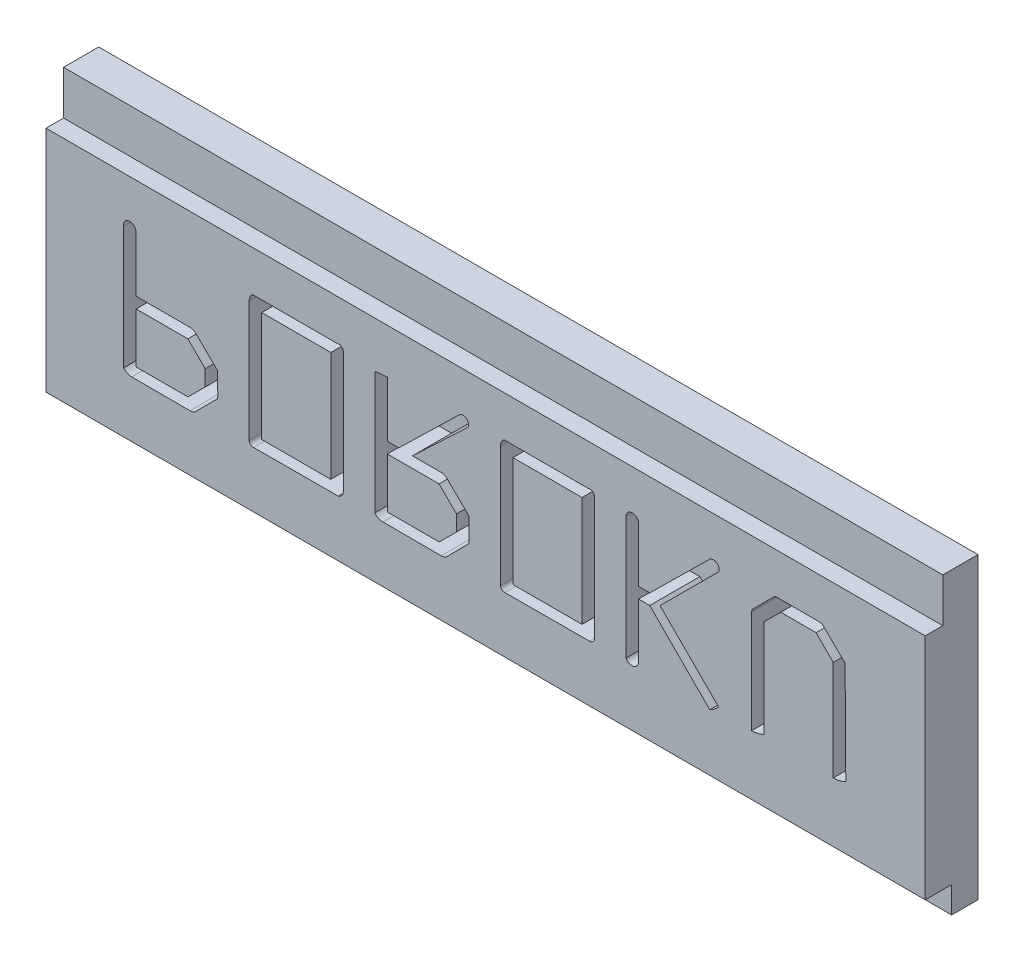
from build123d import *

# Parameters (mm, degrees)
SKETCH1_W           = 100
SKETCH1_H           = 50
BOSS_EXTRUDE1_DEPTH = 6
SKETCH2_W           = 10
SKETCH2_H           = 3
CUT_EXTRUDE1_DEPTH  = 101
SKETCH3_W           = 6
SKETCH3_H           = 34
BOSS_EXTRUDE2_DEPTH = 100
SKETCH4_W           = 2
SKETCH4_H           = 5
CUT_EXTRUDE2_DEPTH  = 101
SKETCH5_W           = 7.857142857
SKETCH5_H           = 12.5
CUT_EXTRUDE3_DEPTH  = 5.7
CUT_EXTRUDE4_DEPTH  = 5.5
CUT_EXTRUDE5_DEPTH  = 101.0000001


with BuildPart() as part:
    # Sketch1 → Boss-Extrude1 (new body)
    with BuildSketch(Plane(origin=(0, 0, 0), x_dir=(1, 0, 0), z_dir=(0, 1, 0))):
        with Locations((50, 25)):
            Rectangle(SKETCH1_W, SKETCH1_H)
    extrude(amount=BOSS_EXTRUDE1_DEPTH)

    # Sketch2 → Cut-Extrude1 (cut, through all)
    with BuildSketch(Plane(origin=(100, 0, 0), x_dir=(0, 0, -1), z_dir=(1, 0, 0))):
        with Locations((5, 1.5)):
            Rectangle(SKETCH2_W, SKETCH2_H)
    extrude(amount=-CUT_EXTRUDE1_DEPTH, mode=Mode.SUBTRACT)

    # Sketch3 → Boss-Extrude2 (add)
    with BuildSketch(Plane(origin=(100, 0, 0), x_dir=(0, 0, -1), z_dir=(1, 0, 0))):
        with Locations((47, 17)):
            Rectangle(SKETCH3_W, SKETCH3_H)
    extrude(amount=-BOSS_EXTRUDE2_DEPTH)

    # Sketch4 → Cut-Extrude2 (cut, through all)
    with BuildSketch(Plane.ZY):
        with Locations((-45, 31.5)):
            Rectangle(SKETCH4_W, SKETCH4_H)
    extrude(amount=-CUT_EXTRUDE2_DEPTH, mode=Mode.SUBTRACT)

    # Sketch5 → Cut-Extrude3 (cut)
    with BuildSketch(Plane(origin=(0, 0, -44), x_dir=(-1, 0, 0), z_dir=(0, 0, -1))):
        with BuildLine():
            Line((-45.088169643, 17.571428571), (-45.439732143, 17.454241071))
            Line((-45.439732143, 17.454241071), (-48.056919643, 14.901227679))
            Line((-48.056919643, 14.901227679), (-48.098772321, 14.76171875))
            Line((-48.098772321, 14.76171875), (-48.107142857, 12.309151786))
            Line((-48.107142857, 12.309151786), (-48.059709821, 12.0859375))
            Line((-48.059709821, 12.0859375), (-45.609933036, 9.619419643))
            ThreePointArc((-45.609933036, 9.619419643), (-45.303061085, 9.424580045), (-44.945870536, 9.357142857))
            Line((-44.945870536, 9.357142857), (-38.319196429, 9.376674107))
            ThreePointArc((-38.319196429, 9.376674107), (-37.810119286, 9.488456034), (-37.392857143, 9.80078125))
            Line((-37.392857143, 9.80078125), (-37.392857143, 23.740513393))
            ThreePointArc((-37.392857143, 23.740513393), (-38.102358714, 23.844903984), (-38.818638393, 23.880022321))
            Line((-38.818638393, 23.880022321), (-38.821428571, 17.571428571))
            Line((-38.821428571, 17.571428571), (-40.116071429, 17.571428571))
            Line((-40.116071429, 17.571428571), (-46.991071429, 24.259486607))
            ThreePointArc((-46.991071429, 24.259486607), (-47.787451466, 24.334800239), (-48.031808036, 23.573102679))
            Line((-48.031808036, 23.573102679), (-41.681361607, 17.571428571))
            Line((-41.681361607, 17.571428571), (-45.088169643, 17.571428571))
        make_face()
        Polygon((-46.678571429, 12.557477679), (-44.725446429, 10.607142857), (-38.821428571, 10.607142857), (-38.821428571, 16.321428571), (-44.708705357, 16.321428571), (-46.678571429, 14.354352679), align=None, mode=Mode.SUBTRACT)
        with BuildLine():
            Line((-17.038504464, 9.619419643), (-19.48828125, 12.0859375))
            Line((-19.48828125, 12.0859375), (-19.535714286, 12.309151786))
            Line((-19.535714286, 12.309151786), (-19.52734375, 14.758928571))
            Line((-19.52734375, 14.758928571), (-19.485491071, 14.904017857))
            Line((-19.485491071, 14.904017857), (-16.896205357, 17.454241071))
            Line((-16.896205357, 17.454241071), (-16.555803571, 17.571428571))
            Line((-16.555803571, 17.571428571), (-10.25, 17.571428571))
            Line((-10.25, 17.571428571), (-10.244419643, 23.868861607))
            ThreePointArc((-10.244419643, 23.868861607), (-9.462763686, 24.582553037), (-8.821428571, 23.740513393))
            Line((-8.821428571, 23.740513393), (-8.821428571, 9.80078125))
            ThreePointArc((-8.821428571, 9.80078125), (-9.238690714, 9.488456034), (-9.747767857, 9.376674107))
            Line((-9.747767857, 9.376674107), (-16.374441964, 9.357142857))
            ThreePointArc((-16.374441964, 9.357142857), (-16.731632514, 9.424580045), (-17.038504464, 9.619419643))
        make_face()
        Polygon((-18.107142857, 12.563058036), (-16.154017857, 10.607142857), (-10.25, 10.607142857), (-10.25, 16.321428571), (-16.137276786, 16.321428571), (-18.107142857, 14.368303571), align=None, mode=Mode.SUBTRACT)
        with BuildLine():
            Line((-33.821428571, 10.1328125), (-33.815848214, 23.880022321))
            ThreePointArc((-33.815848214, 23.880022321), (-33.601713039, 24.293327013), (-33.140625, 24.357142857))
            Line((-33.140625, 24.357142857), (-23.508928571, 24.357142857))
            ThreePointArc((-23.508928571, 24.357142857), (-23.212822653, 23.985866281), (-23.107142857, 23.522879464))
            Line((-23.107142857, 23.522879464), (-23.107142857, 9.78125))
            ThreePointArc((-23.107142857, 9.78125), (-23.280423047, 9.477022359), (-23.609375, 9.357142857))
            Line((-23.609375, 9.357142857), (-33.235491071, 9.379464286))
            ThreePointArc((-33.235491071, 9.379464286), (-33.657785084, 9.655552078), (-33.821428571, 10.1328125))
        make_face()
        with Locations((-28.464285715, 16.857142857)):
            Rectangle(SKETCH5_W, SKETCH5_H, mode=Mode.SUBTRACT)
        with BuildLine():
            Line((-62.392857143, 10.1328125), (-62.387276786, 23.880022321))
            ThreePointArc((-62.387276786, 23.880022321), (-62.17314161, 24.293327013), (-61.712053571, 24.357142857))
            Line((-61.712053571, 24.357142857), (-52.080357143, 24.357142857))
            ThreePointArc((-52.080357143, 24.357142857), (-51.784251224, 23.985866281), (-51.678571429, 23.522879464))
            Line((-51.678571429, 23.522879464), (-51.678571429, 9.78125))
            ThreePointArc((-51.678571429, 9.78125), (-51.851851619, 9.477022359), (-52.180803571, 9.357142857))
            Line((-52.180803571, 9.357142857), (-61.806919643, 9.379464286))
            ThreePointArc((-61.806919643, 9.379464286), (-62.283572717, 9.613272807), (-62.392857143, 10.1328125))
        make_face()
        with Locations((-57.035714286, 16.857142857)):
            Rectangle(SKETCH5_W, SKETCH5_H, mode=Mode.SUBTRACT)
        with BuildLine():
            Line((-76.516741071, 10.224888393), (-69.834263393, 16.890625))
            Line((-69.834263393, 16.890625), (-76.508370536, 23.564732143))
            ThreePointArc((-76.508370536, 23.564732143), (-76.263865977, 24.33823157), (-75.456473214, 24.259486607))
            Line((-75.456473214, 24.259486607), (-68.670758929, 17.571428571))
            Line((-68.670758929, 17.571428571), (-67.392857143, 17.571428571))
            Line((-67.392857143, 17.571428571), (-67.390066964, 23.880022321))
            ThreePointArc((-67.390066964, 23.880022321), (-66.613914042, 24.456808533), (-65.964285714, 23.740513393))
            Line((-65.964285714, 23.740513393), (-65.964285714, 9.789620536))
            ThreePointArc((-65.964285714, 9.789620536), (-66.815504738, 9.403127861), (-67.392857143, 10.138392857))
            Line((-67.392857143, 10.138392857), (-67.392857143, 16.321428571))
            Line((-67.392857143, 16.321428571), (-68.66796875, 16.321428571))
            Line((-68.66796875, 16.321428571), (-75.489955357, 9.465959821))
            ThreePointArc((-75.489955357, 9.465959821), (-76.031889018, 9.806810078), (-76.516741071, 10.224888393))
        make_face()
        with BuildLine():
            Line((-81.678571429, 10.130022321), (-81.678571429, 21.2265625))
            Line((-81.678571429, 21.2265625), (-83.5703125, 23.107142857))
            Line((-83.5703125, 23.107142857), (-87.585379464, 23.107142857))
            Line((-87.585379464, 23.107142857), (-89.535714286, 21.151227679))
            Line((-89.535714286, 21.151227679), (-89.535714286, 9.770089286))
            ThreePointArc((-89.535714286, 9.770089286), (-90.273009404, 9.862916097), (-90.964285714, 10.135602679))
            Line((-90.964285714, 10.135602679), (-90.883370536, 21.751116071))
            Line((-90.883370536, 21.751116071), (-88.2578125, 24.320870536))
            Line((-88.2578125, 24.320870536), (-87.872767857, 24.357142857))
            Line((-87.872767857, 24.357142857), (-82.970424107, 24.357142857))
            Line((-82.970424107, 24.357142857), (-82.7890625, 24.234375))
            Line((-82.7890625, 24.234375), (-80.303013393, 21.742745536))
            Line((-80.303013393, 21.742745536), (-80.25, 21.48046875))
            Line((-80.25, 21.48046875), (-80.25, 9.78125))
            ThreePointArc((-80.25, 9.78125), (-80.985264996, 9.869705022), (-81.678571429, 10.130022321))
        make_face()
    extrude(amount=CUT_EXTRUDE3_DEPTH, mode=Mode.SUBTRACT)

    # Sketch8 → Cut-Extrude4 (cut)
    with BuildSketch(Plane(origin=(0, 6, 0), x_dir=(1, 0, 0), z_dir=(0, 1, 0))):
        with BuildLine():
            Line((7.011617647, 30.077205882), (8.955082743, 27.33260299))
            add(Edge.make_bspline(
                [(8.955082743, 27.33260299), (9.12959235, 26.730722395), (8.207708735, 26.573406529), (7.899470003, 26.933823529)],
                knots=[0, 0, 0, 0, 1, 1, 1, 1], degree=3))
            add(Edge.make_bspline(
                [(7.899470003, 26.933823529), (6.967481131, 27.995956124), (6.173874947, 29.162344961)],
                knots=[0, 0, 0, 1, 1, 1], degree=2))
            add(Edge.make_bspline(
                [(6.173874947, 29.162344961), (5.827065663, 29.66494419), (6.530628947, 30.242627585), (7.011617647, 30.077205882)],
                knots=[0, 0, 0, 0, 1, 1, 1, 1], degree=3))
        make_face()
        with BuildLine():
            Line((8.476184036, 31.013434386), (10.320441176, 28.506054806))
            add(Edge.make_bspline(
                [(10.320441176, 28.506054806), (10.75287522, 28.022402696), (9.844480118, 27.32594185), (9.464423283, 27.806698869)],
                knots=[0, 0, 0, 0, 1, 1, 1, 1], degree=3))
            add(Edge.make_bspline(
                [(7.548449232, 30.408088235), (8.369245022, 29.00368602), (9.464423283, 27.806698869)],
                knots=[0, 0, 0, 1, 1, 1], degree=2))
            add(Edge.make_bspline(
                [(7.548449232, 30.408088235), (7.420862108, 30.780822958), (7.657281624, 31.572935659), (8.169705882, 31.400735294)],
                knots=[0, 0, 0, 0, 1, 1, 1, 1], degree=3))
            add(Edge.make_bspline(
                [(8.169705882, 31.400735294), (8.365163665, 31.240936083), (8.476184036, 31.013434386)],
                knots=[0, 0, 0, 1, 1, 1], degree=2))
        make_face()
        Polygon((10.816764706, 31.400735294), (10.155, 32.724264706), (9.327794118, 32.393382353), (9.162352941, 31.235294118), (9.824117647, 30.408088235), align=None)
        with BuildLine():
            Line((12.802058824, 32.227941176), (11.643970588, 33.716911765))
            add(Edge.make_bspline(
                [(11.643970588, 33.716911765), (10.801410064, 33.411012177), (11.092331374, 32.550744981)],
                knots=[0, 0, 0, 1, 1, 1], degree=2))
            Line((11.092331374, 32.550744981), (11.643970588, 31.731617647))
            Line((11.643970588, 31.731617647), (12.802058824, 32.227941176))
        make_face()
        with BuildLine():
            Line((13.193009945, 29.973529412), (13.854774651, 28.815441176))
            Line((13.854774651, 28.815441176), (8.560657004, 26.333823529))
            Line((8.560657004, 26.333823529), (7.402568768, 26.830147059))
            Line((7.402568768, 26.830147059), (9.056980533, 19.881617647))
            Line((9.056980533, 19.881617647), (13.689333474, 20.047058824))
            add(Edge.make_bspline(
                [(13.689333474, 20.047058824), (12.450227116, 27.171920383), (13.777231511, 23.836713066), (15.840068768, 28.65)],
                knots=[0, 0, 0, 0, 1, 1, 1, 1], degree=3))
            Line((15.840068768, 28.65), (13.854774651, 31.627941176))
            Line((13.854774651, 31.627941176), (10.711392298, 30.138970588))
            Line((10.711392298, 30.138970588), (12.365804063, 29.477205882))
            Line((12.365804063, 29.477205882), (13.193009945, 29.973529412))
        make_face()
        Polygon((31.240068768, 25.85), (31.240068768, 28.65), (28.440068768, 28.65), (28.440068768, 31.45), (25.640068768, 31.45), (25.640068768, 28.65), (22.840068768, 28.65), (22.840068768, 25.85), (25.640068768, 25.85), (25.640068768, 23.05), (28.440068768, 23.05), (28.440068768, 25.85), align=None)
        Polygon((52.041417767, 30.75), (42.541417767, 30.75), (42.541417767, 33.75), (37.990068768, 27.25), (42.541417767, 20.75), (42.541417767, 23.75), (52.041417767, 23.75), align=None)
        Polygon((60.419322104, 21.339322104), (59.041417767, 29.153805922), (61.16273811, 27.032485579), (67.880252532, 33.75), (72.83, 28.800252532), (66.112485579, 22.08273811), (68.233805922, 19.961417767), align=None)
        Polygon((90.03, 33.75), (90.03, 24.25), (93.03, 24.25), (86.476783646, 19.661388509), (80.03, 24.25), (83.03, 24.25), (83.03, 33.75), align=None)
    extrude(amount=-CUT_EXTRUDE4_DEPTH, mode=Mode.SUBTRACT)

    # Sketch9 → Cut-Extrude5 (cut, through all)
    with BuildSketch(Plane.ZY):
        Polygon((0, 6), (-44, 6), (-44, 3), (-47, 3), (-47, 0), (-44, 0), (0, 0), align=None)
    extrude(amount=-CUT_EXTRUDE5_DEPTH, mode=Mode.SUBTRACT)


solid = part.part
